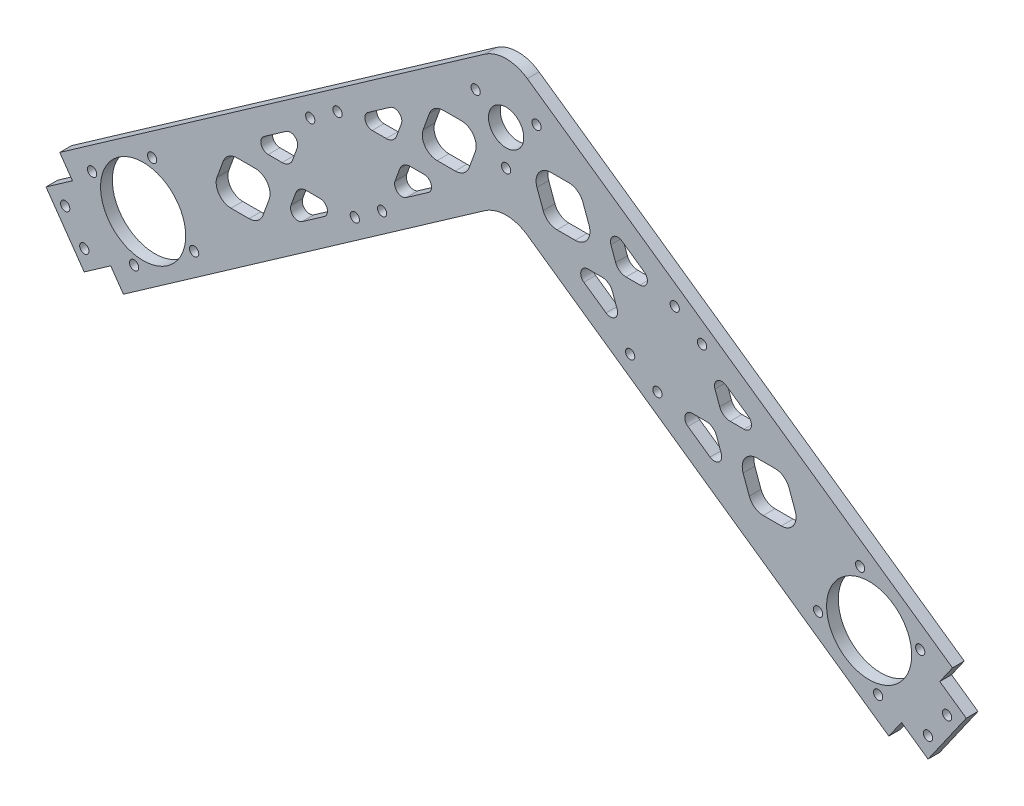
from build123d import *

# Parameters (mm, degrees)
BASE_DEPTH           = 3.175
SKETCH3_R            = 4.7625
SKETCH3_R_2          = 1.25
FASTENERS_DEPTH      = 4.175
FILLET1_R            = 10
TOPOLOGY_HOLES_DEPTH = 4.175
SKETCH6_R            = 1.25
SUPPORTS_DEPTH       = 4.175
SKETCH8_R            = 11.5
SKETCH8_R_2          = 1.25
MOTOR_PLATE_DEPTH    = 4.175
SKETCH12_R           = 1.25
PLATE_SUPPORT_DEPTH  = 3.175


with BuildPart() as part:
    # Base Sketch → Base (new body)
    with BuildSketch(Plane.XY):
        Polygon((0, 0), (-17.207293091, 24.574561329), (103.396353455, 109.022143775), (224, 24.574561329), (206.792706909, 0), (103.396353455, 72.398906112), align=None)
    extrude(amount=BASE_DEPTH)

    # Sketch3 → Fasteners (cut, through all)
    with BuildSketch(Plane.XY.offset(3.175)):
        with Locations((103.396353455, 90.710524944)):
            Circle(SKETCH3_R)
        with Locations((103.396353455, 81.198024944)):
            Circle(SKETCH3_R_2)
        with Locations((111.634420108, 95.466774944)):
            Circle(SKETCH3_R_2)
        with Locations((95.158286801, 95.466774944)):
            Circle(SKETCH3_R_2)
    extrude(amount=-FASTENERS_DEPTH, mode=Mode.SUBTRACT)

    # Fillet1
    fillet1_edges = [part.edges().sort_by_distance(p)[0] for p in [
        (103.396353455, 109.022143775, 1.5875),
        (103.396353455, 72.398906112, 1.5875),
    ]]
    fillet(fillet1_edges, radius=FILLET1_R)

    # Sketch5 → Topology Holes (cut, through all)
    with BuildSketch(Plane.XY.offset(3.175)):
        with BuildLine():
            Line((45.265276935, 43.461284839), (46.55138053, 46.994825426))
            ThreePointArc((46.55138053, 46.994825426), (47.649729084, 48.426221129), (49.370458393, 48.968764996))
            Line((49.370458393, 48.968764996), (53.130773743, 48.968764996))
            ThreePointArc((53.130773743, 48.968764996), (55.038207644, 47.570176595), (54.277926615, 45.330460907))
            Line((54.277926615, 45.330460907), (48.29181505, 41.138940464))
            ThreePointArc((48.29181505, 41.138940464), (45.927139319, 41.190537872), (45.265276935, 43.461284839))
        make_face()
        with BuildLine():
            Line((33.938973564, 34.656761682), (29.055875209, 34.656761682))
            ThreePointArc((29.055875209, 34.656761682), (25.779267032, 36.362455937), (25.297104726, 40.024842255))
            Line((25.297104726, 40.024842255), (26.967222725, 44.613453746))
            ThreePointArc((26.967222725, 44.613453746), (28.431687463, 46.52198135), (30.725993208, 47.245373173))
            Line((30.725993208, 47.245373173), (35.609091563, 47.245373173))
            ThreePointArc((35.609091563, 47.245373173), (38.88569974, 45.539678918), (39.367862046, 41.8772926))
            Line((39.367862046, 41.8772926), (37.697744047, 37.288681109))
            ThreePointArc((37.697744047, 37.288681109), (36.233279309, 35.380153505), (33.938973564, 34.656761682))
        make_face()
        with BuildLine():
            Line((45.69398528, 54.219312743), (46.980088875, 57.752853329))
            ThreePointArc((46.980088875, 57.752853329), (46.318226492, 60.023600296), (43.953550761, 60.075197704))
            Line((43.953550761, 60.075197704), (37.967439195, 55.883677261))
            ThreePointArc((37.967439195, 55.883677261), (37.207158167, 53.643961574), (39.114592068, 52.245373173))
            Line((39.114592068, 52.245373173), (42.874907418, 52.245373173))
            ThreePointArc((42.874907418, 52.245373173), (44.595636727, 52.78791704), (45.69398528, 54.219312743))
        make_face()
        with BuildLine():
            Line((84.750405047, 73.654491311), (89.633503402, 73.654491311))
            ThreePointArc((89.633503402, 73.654491311), (91.927809147, 74.377883134), (93.392273885, 76.286410738))
            Line((93.392273885, 76.286410738), (95.062391884, 80.875022229))
            ThreePointArc((95.062391884, 80.875022229), (94.580229578, 84.537408548), (91.303621401, 86.243102802))
            Line((91.303621401, 86.243102802), (86.420523046, 86.243102802))
            ThreePointArc((86.420523046, 86.243102802), (84.1262173, 85.519710979), (82.661752563, 83.611183375))
            Line((82.661752563, 83.611183375), (80.991634563, 79.022571885))
            ThreePointArc((80.991634563, 79.022571885), (81.473796869, 75.360185566), (84.750405047, 73.654491311))
        make_face()
        with BuildLine():
            Line((75.094219674, 77.438579645), (73.808116079, 73.905039059))
            ThreePointArc((73.808116079, 73.905039059), (72.709767526, 72.473643356), (70.989038217, 71.931099489))
            Line((70.989038217, 71.931099489), (67.228722867, 71.931099489))
            ThreePointArc((67.228722867, 71.931099489), (65.321288966, 73.32968789), (66.081569994, 75.569403577))
            Line((66.081569994, 75.569403577), (72.06768156, 79.76092402))
            ThreePointArc((72.06768156, 79.76092402), (74.432357291, 79.709326612), (75.094219674, 77.438579645))
        make_face()
        with BuildLine():
            Line((74.665511329, 66.680551741), (73.379407734, 63.147011155))
            ThreePointArc((73.379407734, 63.147011155), (74.041270118, 60.876264188), (76.405945849, 60.82466678))
            Line((76.405945849, 60.82466678), (82.392057414, 65.016187223))
            ThreePointArc((82.392057414, 65.016187223), (83.152338443, 67.25590291), (81.244904542, 68.654491311))
            Line((81.244904542, 68.654491311), (77.484589192, 68.654491311))
            ThreePointArc((77.484589192, 68.654491311), (75.763859883, 68.111947444), (74.665511329, 66.680551741))
        make_face()
    topology_holes = extrude(amount=-TOPOLOGY_HOLES_DEPTH, mode=Mode.SUBTRACT)

    # Sketch6 → Supports (cut, through all)
    with BuildSketch(Plane.XY.offset(3.175)):
        with Locations((69.888485086, 54.429929741)):
            Circle(SKETCH6_R)
        with Locations((62.516116687, 49.267741813)):
            Circle(SKETCH6_R)
        with Locations((50.471011524, 66.469934744)):
            Circle(SKETCH6_R)
        with Locations((57.843379923, 71.632122671)):
            Circle(SKETCH6_R)
        with Locations((148.949326987, 71.632122671)):
            Circle(SKETCH6_R)
        with Locations((156.321695386, 66.469934744)):
            Circle(SKETCH6_R)
        with Locations((144.276590222, 49.267741813)):
            Circle(SKETCH6_R)
        with Locations((136.904221824, 54.429929741)):
            Circle(SKETCH6_R)
    extrude(amount=-SUPPORTS_DEPTH, mode=Mode.SUBTRACT)

    # Mirror1: Topology Holes across plane
    add(topology_holes.mirror(Plane(origin=(103.396353455, 0, 0), x_dir=(0, 0, 1), z_dir=(1, 0, 0))), mode=Mode.SUBTRACT)

    # Sketch8 → Motor Plate (cut, through all)
    with BuildSketch(Plane.XY.offset(3.175)):
        with Locations((5.321938208, 22.038080082)):
            Circle(SKETCH8_R)
        with Locations((-8.465370335, 24.46915457)):
            Circle(SKETCH8_R_2)
        with Locations((7.753012695, 35.825388624)):
            Circle(SKETCH8_R_2)
        with Locations((19.10924675, 19.607005595)):
            Circle(SKETCH8_R_2)
        with Locations((2.89086372, 8.25077154)):
            Circle(SKETCH8_R_2)
        with Locations((203.901843189, 8.25077154)):
            Circle(SKETCH8_R_2)
        with Locations((215.258077244, 24.46915457)):
            Circle(SKETCH8_R_2)
        with Locations((199.039694214, 35.825388624)):
            Circle(SKETCH8_R_2)
        with Locations((187.68346016, 19.607005595)):
            Circle(SKETCH8_R_2)
        with Locations((201.470768702, 22.038080082)):
            Circle(SKETCH8_R)
    extrude(amount=-MOTOR_PLATE_DEPTH, mode=Mode.SUBTRACT)

    # Sketch12 → Plate Support (add)
    with BuildSketch(Plane.XY.offset(3.175)):
        Polygon((-3.441458618, 4.914912266), (-10.593055004, -0.092689434), (-20.917430859, 14.652047363), (-13.765834472, 19.659649063), align=None)
        with Locations((-10.573341227, 5.414599951)):
            Circle(SKETCH12_R, mode=Mode.SUBTRACT)
        with Locations((-15.735529154, 12.786968349)):
            Circle(SKETCH12_R, mode=Mode.SUBTRACT)
        Polygon((210.234165528, 4.914912266), (217.385761914, -0.092689434), (227.710137768, 14.652047363), (220.558541382, 19.659649063), align=None)
        with Locations((217.366048137, 5.414599951)):
            Circle(SKETCH12_R, mode=Mode.SUBTRACT)
        with Locations((222.528236064, 12.786968349)):
            Circle(SKETCH12_R, mode=Mode.SUBTRACT)
    extrude(amount=-PLATE_SUPPORT_DEPTH)


solid = part.part
